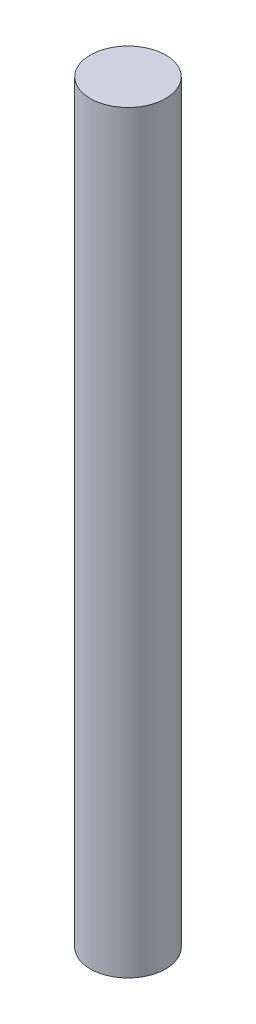
from build123d import *

# Parameters (mm, degrees)
SKETCH2_R           = 0.1
BOSS_EXTRUDE2_DEPTH = 2


with BuildPart() as part:
    # Sketch2 → Boss-Extrude2 (new body)
    with BuildSketch(Plane(origin=(0, 0, 0), x_dir=(1, 0, 0), z_dir=(0, 1, 0))):
        Circle(SKETCH2_R)
    extrude(amount=BOSS_EXTRUDE2_DEPTH)


solid = part.part
